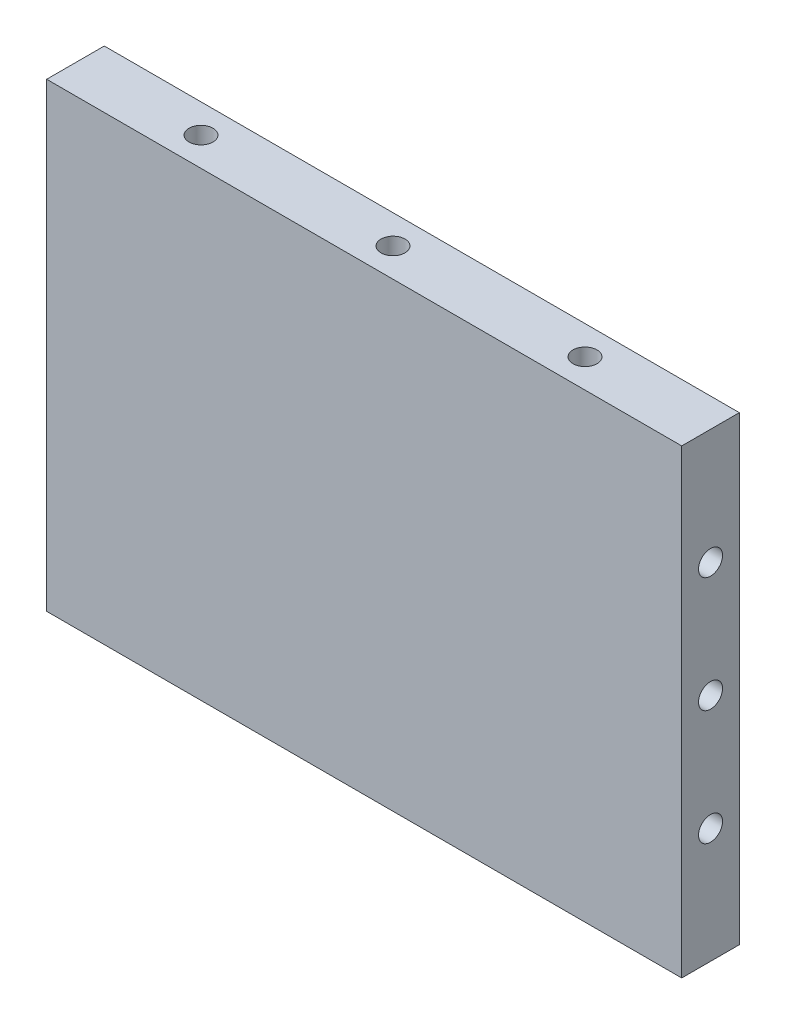
from build123d import *

# Parameters (mm, degrees)
SKETCH_1_W         = 66.15
SKETCH_1_H         = 48
EXTRUDE_1_DEPTH    = 6
HOLE_WIZARD_M3_2_D = 2.5
HOLE_WIZARD_M3_3_D = 2.5


with BuildPart() as part:
    # 草图1 → 凸台-拉伸1 (new body)
    with BuildSketch(Plane.XY):
        Rectangle(SKETCH_1_W, SKETCH_1_H)
    extrude(amount=EXTRUDE_1_DEPTH)

    # M3 螺纹孔2 (through all)
    with Locations(Plane.ZY.offset(33.075)):
        with Locations((3, 12), (3, -12), (3, 0)):
            Hole(HOLE_WIZARD_M3_2_D / 2)

    # M3 螺纹孔3 (through all)
    with Locations(Plane(origin=(0, 24, 0), x_dir=(1, 0, 0), z_dir=(0, 1, 0))):
        with Locations((0, -3), (20, -3), (-20, -3)):
            Hole(HOLE_WIZARD_M3_3_D / 2)


solid = part.part
